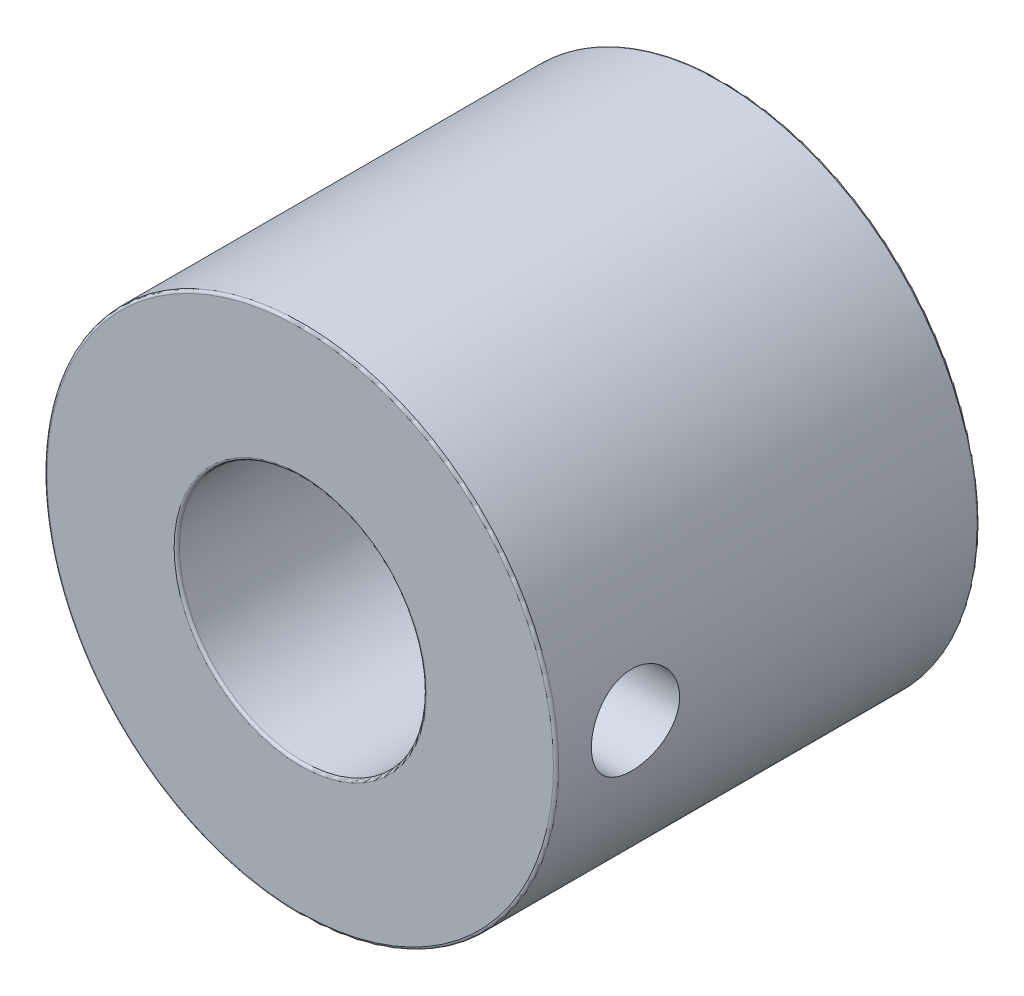
from build123d import *

# Parameters (mm, degrees)
SKETCH4_R               = 29
BOSS_EXTRUDE1_DEPTH     = 48
SKETCH5_R               = 24
CUT_EXTRUDE1_DEPTH      = 25
SKETCH6_R               = 14
CUT_EXTRUDE2_DEPTH      = 1
CUT_EXTRUDE2_DEPTH_BACK = 49
SKETCH7_R               = 5
CUT_EXTRUDE3_DEPTH      = 42
FILLET1_R               = 0.3


with BuildPart() as part:
    # Sketch4 → Boss-Extrude1 (new body)
    with BuildSketch(Plane.XY):
        Circle(SKETCH4_R)
    extrude(amount=BOSS_EXTRUDE1_DEPTH)

    # Sketch5 → Cut-Extrude1 (cut)
    with BuildSketch(Plane(origin=(0, 0, 0), x_dir=(-1, 0, 0), z_dir=(0, 0, -1))):
        Circle(SKETCH5_R)
    extrude(amount=-CUT_EXTRUDE1_DEPTH, mode=Mode.SUBTRACT)

    # Sketch6 → Cut-Extrude2 (cut, two sides)
    with BuildSketch(Plane.XY.offset(48)) as cut_extrude2_sk:
        Circle(SKETCH6_R)
    extrude(amount=CUT_EXTRUDE2_DEPTH, mode=Mode.SUBTRACT)
    extrude(cut_extrude2_sk.sketch, amount=-CUT_EXTRUDE2_DEPTH_BACK, mode=Mode.SUBTRACT)

    # Sketch7 → Cut-Extrude3 (cut)
    with BuildSketch(Plane(origin=(0, 0, 0), x_dir=(0, 0, -1), z_dir=(1, 0, 0))):
        with Locations((-39, 0)):
            Circle(SKETCH7_R)
    extrude(amount=CUT_EXTRUDE3_DEPTH, mode=Mode.SUBTRACT)

    # Fillet1
    fillet1_edges = [part.edges().sort_by_distance(p)[0] for p in [
        (-14, 0, 48),
        (-14, 0, 25),
        (-29, 0, 0),
        (-29, 0, 48),
    ]]
    fillet(fillet1_edges, radius=FILLET1_R)


solid = part.part
